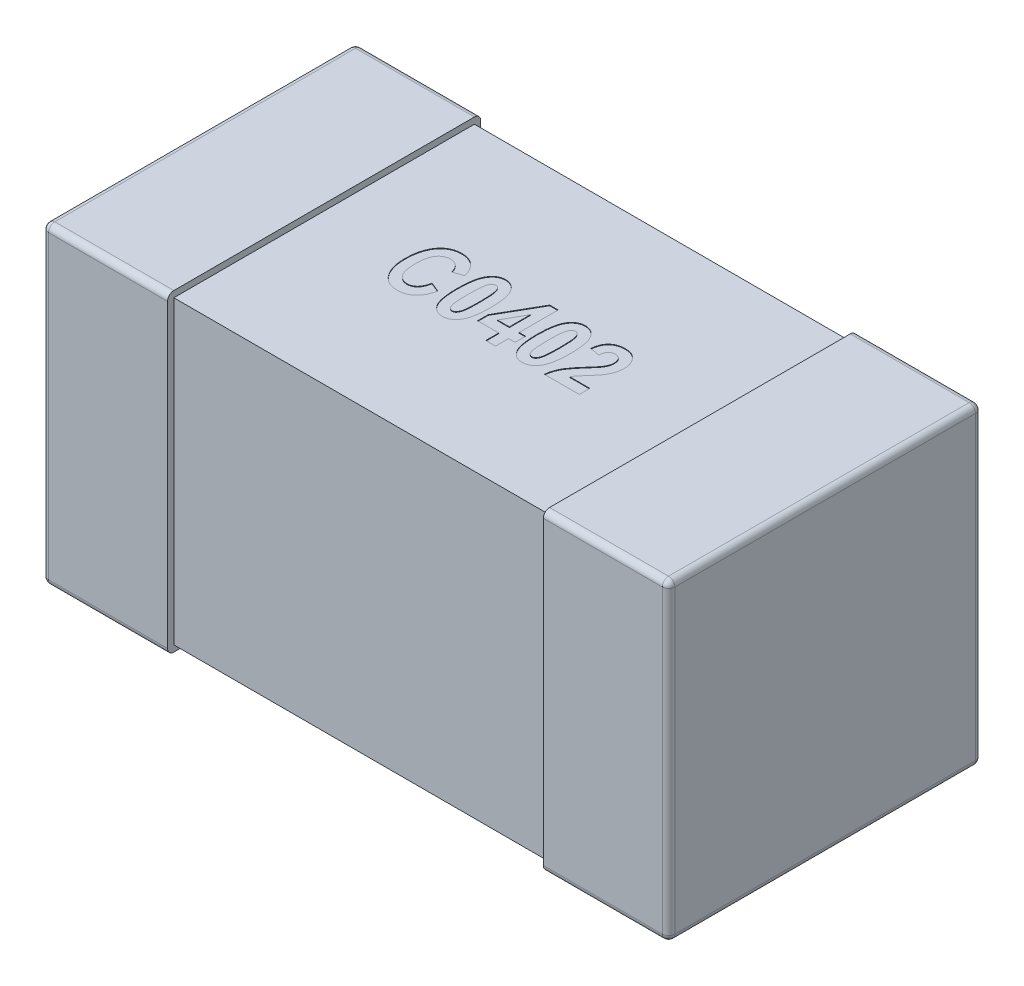
from build123d import *

# Parameters (mm, degrees)
SKETCH1_W            = 0.2
SKETCH1_H            = 0.5
THICKNESS_DEPTH      = 0.5
FILLET1_R            = 0.01
SKETCH2_W            = 0.48
SKETCH2_H            = 0.48
BOSS_EXTRUDE2_DEPTH  = 0.3
FILLET1_OF_MIRROR3_R = 0.01
CUT_EXTRUDE1_DEPTH   = 0.001


with BuildPart() as part:
    # Sketch1 → THICKNESS (new body)
    with BuildSketch(Plane(origin=(0, 0, 0), x_dir=(1, 0, 0), z_dir=(0, 1, 0))):
        with Locations((-0.4, 0)):
            Rectangle(SKETCH1_W, SKETCH1_H)
    thickness = extrude(amount=THICKNESS_DEPTH)

    # Fillet1
    fillet1_edges = [part.edges().sort_by_distance(p)[0] for p in [
        (-0.4, 0.5, -0.25),
        (-0.5, 0.5, 0),
        (-0.4, 0, -0.25),
        (-0.4, 0, 0.25),
        (-0.5, 0, 0),
        (-0.4, 0.5, 0.25),
        (-0.5, 0.25, -0.25),
        (-0.5, 0.25, 0.25),
    ]]
    fillet(fillet1_edges, radius=FILLET1_R)

    # Sketch2 → Boss-Extrude2 (add)
    with BuildSketch(Plane(origin=(0, 0, 0), x_dir=(0, 0, -1), z_dir=(1, 0, 0))):
        with Locations((0, 0.25)):
            Rectangle(SKETCH2_W, SKETCH2_H)
    boss_extrude2 = extrude(amount=-BOSS_EXTRUDE2_DEPTH)

    # Mirror3: THICKNESS, Boss-Extrude2 across plane
    add(thickness.mirror(Plane(origin=(0, 0, 0), x_dir=(0, 0, 1), z_dir=(1, 0, 0))))
    add(boss_extrude2.mirror(Plane(origin=(0, 0, 0), x_dir=(0, 0, 1), z_dir=(1, 0, 0))))

    # Fillet1 of Mirror3
    fillet1_of_mirror3_edges = [part.edges().sort_by_distance(p)[0] for p in [
        (0.4, 0.5, -0.25),
        (0.5, 0.5, 0),
        (0.4, 0, -0.25),
        (0.4, 0, 0.25),
        (0.5, 0, 0),
        (0.4, 0.5, 0.25),
        (0.5, 0.25, -0.25),
        (0.5, 0.25, 0.25),
    ]]
    fillet(fillet1_of_mirror3_edges, radius=FILLET1_OF_MIRROR3_R)

    # Sketch3 → Cut-Extrude1 (cut)
    with BuildSketch(Plane(origin=(0, 0.49, 0), x_dir=(1, 0, 0), z_dir=(0, 1, 0))):
        with BuildLine():
            Line((-0.113961039, -0.013636364), (-0.098376623, -0.02012987))
            add(Edge.make_bspline(
                [(-0.098376623, -0.02012987), (-0.098698486, -0.021439884), (-0.099325651, -0.02399251), (-0.100512161, -0.027640931), (-0.10181778, -0.031026109), (-0.103311482, -0.034129098), (-0.104942054, -0.03697712), (-0.106753288, -0.03954215), (-0.108711107, -0.041837321), (-0.110826647, -0.04385727), (-0.113096477, -0.045595275), (-0.115456865, -0.047144014), (-0.117968765, -0.04841365), (-0.120597002, -0.049485662), (-0.123362239, -0.050282525), (-0.126243467, -0.050882197), (-0.129253053, -0.051225358), (-0.131303272, -0.051273978), (-0.132345779, -0.051298701)],
                knots=[0, 0, 0, 0, 4.046e-06, 7.883e-06, 1.1501e-05, 1.4922e-05, 1.8205e-05, 2.1335e-05, 2.4328e-05, 2.7242e-05, 3.0091e-05, 3.2894e-05, 3.5699e-05, 3.8521e-05, 4.1398e-05, 4.4319e-05, 4.7342e-05, 5.0469e-05, 5.0469e-05, 5.0469e-05, 5.0469e-05], degree=3))
            add(Edge.make_bspline(
                [(-0.132345779, -0.051298701), (-0.133653808, -0.051269294), (-0.136216205, -0.051211685), (-0.139955235, -0.050591826), (-0.143513244, -0.049650059), (-0.146883819, -0.048297676), (-0.150070956, -0.046569042), (-0.153040987, -0.044427876), (-0.155863213, -0.041953888), (-0.157504143, -0.040024907), (-0.158340097, -0.039042208)],
                knots=[0, 0, 0, 0, 3.921e-06, 7.68e-06, 1.1338e-05, 1.4944e-05, 1.8549e-05, 2.2186e-05, 2.5909e-05, 2.9775e-05, 2.9775e-05, 2.9775e-05, 2.9775e-05], degree=3))
            add(Edge.make_bspline(
                [(-0.158340097, -0.039042208), (-0.159258979, -0.037828943), (-0.161110151, -0.035384708), (-0.163434195, -0.03135417), (-0.165410839, -0.027024034), (-0.167028624, -0.022390376), (-0.168289603, -0.017448062), (-0.16917119, -0.012194736), (-0.169700611, -0.006632938), (-0.169769805, -0.0028218), (-0.169805195, -0.000872565)],
                knots=[0, 0, 0, 0, 4.562e-06, 9.191e-06, 1.3922e-05, 1.8825e-05, 2.3894e-05, 2.9205e-05, 3.479e-05, 4.0637e-05, 4.0637e-05, 4.0637e-05, 4.0637e-05], degree=3))
            add(Edge.make_bspline(
                [(-0.169805195, -0.000872565), (-0.169772864, 0.001185129), (-0.169709888, 0.00519317), (-0.169142885, 0.011028498), (-0.168278515, 0.016529823), (-0.166989774, 0.021676699), (-0.165375342, 0.026498678), (-0.163380716, 0.030965691), (-0.161064755, 0.035124457), (-0.159175196, 0.037608213), (-0.158238636, 0.038839286)],
                knots=[0, 0, 0, 0, 6.172e-06, 1.2021e-05, 1.7572e-05, 2.2863e-05, 2.792e-05, 3.2807e-05, 3.7524e-05, 4.2159e-05, 4.2159e-05, 4.2159e-05, 4.2159e-05], degree=3))
            add(Edge.make_bspline(
                [(-0.158238636, 0.038839286), (-0.157388286, 0.039834414), (-0.155712429, 0.041795598), (-0.15284799, 0.044335194), (-0.149770684, 0.046493942), (-0.146481623, 0.048261407), (-0.142966091, 0.049636084), (-0.139241293, 0.050606078), (-0.135292315, 0.051178413), (-0.132591184, 0.051257992), (-0.131209416, 0.051298701)],
                knots=[0, 0, 0, 0, 3.923e-06, 7.732e-06, 1.1447e-05, 1.5178e-05, 1.8905e-05, 2.2744e-05, 2.6702e-05, 3.0846e-05, 3.0846e-05, 3.0846e-05, 3.0846e-05], degree=3))
            add(Edge.make_bspline(
                [(-0.131209416, 0.051298701), (-0.130078625, 0.051271634), (-0.127856109, 0.051218435), (-0.124597192, 0.05079314), (-0.121492273, 0.050045317), (-0.118511042, 0.049064406), (-0.115679656, 0.047751959), (-0.112989928, 0.04615938), (-0.110431279, 0.044291905), (-0.108880442, 0.042840118), (-0.108096591, 0.042106331)],
                knots=[0, 0, 0, 0, 3.392e-06, 6.666e-06, 9.836e-06, 1.2961e-05, 1.6066e-05, 1.9178e-05, 2.2327e-05, 2.5546e-05, 2.5546e-05, 2.5546e-05, 2.5546e-05], degree=3))
            add(Edge.make_bspline(
                [(-0.108096591, 0.042106331), (-0.107551587, 0.041540788), (-0.106441022, 0.04038837), (-0.104945644, 0.038447195), (-0.103561183, 0.036309366), (-0.102312462, 0.033965761), (-0.101151565, 0.031439285), (-0.100095942, 0.028716989), (-0.099167288, 0.025792679), (-0.09864425, 0.02376486), (-0.098376623, 0.022727273)],
                knots=[0, 0, 0, 0, 2.355e-06, 4.798e-06, 7.337e-06, 9.988e-06, 1.2757e-05, 1.5674e-05, 1.8742e-05, 2.1956e-05, 2.1956e-05, 2.1956e-05, 2.1956e-05], degree=3))
            Line((-0.098376623, 0.022727273), (-0.113961039, 0.017532468))
            add(Edge.make_bspline(
                [(-0.113961039, 0.017532468), (-0.114107485, 0.01819759), (-0.114392444, 0.019491808), (-0.11496457, 0.021359541), (-0.115661111, 0.023094294), (-0.116418956, 0.024737712), (-0.117331528, 0.026232951), (-0.118286107, 0.027651456), (-0.11940544, 0.028908196), (-0.120587985, 0.030069208), (-0.121875452, 0.031072515), (-0.123193291, 0.03197985), (-0.124580791, 0.032734233), (-0.126032164, 0.033340946), (-0.127530221, 0.03383196), (-0.129086123, 0.034177253), (-0.13069631, 0.034386351), (-0.131790487, 0.034405743), (-0.132345779, 0.034415584)],
                knots=[0, 0, 0, 0, 2.043e-06, 3.975e-06, 5.851e-06, 7.648e-06, 9.395e-06, 1.1101e-05, 1.277e-05, 1.4434e-05, 1.6066e-05, 1.7659e-05, 1.923e-05, 2.0794e-05, 2.2373e-05, 2.3953e-05, 2.5569e-05, 2.7234e-05, 2.7234e-05, 2.7234e-05, 2.7234e-05], degree=3))
            add(Edge.make_bspline(
                [(-0.132345779, 0.034415584), (-0.133131655, 0.034392284), (-0.134678339, 0.034346427), (-0.136944365, 0.033981575), (-0.139088333, 0.033336255), (-0.141142522, 0.032489077), (-0.143072413, 0.031360384), (-0.144899491, 0.02999352), (-0.146574628, 0.028347179), (-0.14818007, 0.026495327), (-0.149634872, 0.024349724), (-0.150870098, 0.021869978), (-0.151888935, 0.01906494), (-0.152766544, 0.01595473), (-0.153423156, 0.012518912), (-0.153878825, 0.008762806), (-0.154163213, 0.004691861), (-0.154201149, 0.001867371), (-0.154220779, 0.000405844)],
                knots=[0, 0, 0, 0, 2.357e-06, 4.639e-06, 6.861e-06, 9.061e-06, 1.1289e-05, 1.355e-05, 1.5889e-05, 1.8321e-05, 2.0893e-05, 2.3643e-05, 2.6609e-05, 2.9834e-05, 3.3328e-05, 3.7091e-05, 4.118e-05, 4.5564e-05, 4.5564e-05, 4.5564e-05, 4.5564e-05], degree=3))
            add(Edge.make_bspline(
                [(-0.154220779, 0.000405844), (-0.154198598, -0.001109587), (-0.154155885, -0.004027849), (-0.1539069, -0.008242797), (-0.15343364, -0.012115369), (-0.15282783, -0.015660792), (-0.151998836, -0.018858342), (-0.15098606, -0.021709979), (-0.149819503, -0.024243541), (-0.148427925, -0.026425789), (-0.14688603, -0.028309718), (-0.145246714, -0.029945379), (-0.143478327, -0.031311746), (-0.141628178, -0.032469734), (-0.139645475, -0.033347227), (-0.137553673, -0.033944253), (-0.135365177, -0.034357187), (-0.133862911, -0.034395858), (-0.133096591, -0.034415584)],
                knots=[0, 0, 0, 0, 4.547e-06, 8.755e-06, 1.2659e-05, 1.6246e-05, 1.9538e-05, 2.2555e-05, 2.5314e-05, 2.7887e-05, 3.0296e-05, 3.2606e-05, 3.4818e-05, 3.6986e-05, 3.9139e-05, 4.1297e-05, 4.3502e-05, 4.5798e-05, 4.5798e-05, 4.5798e-05, 4.5798e-05], degree=3))
            add(Edge.make_bspline(
                [(-0.133096591, -0.034415584), (-0.13253456, -0.034398178), (-0.131419647, -0.034363648), (-0.129779044, -0.034143775), (-0.128195889, -0.033750644), (-0.126669969, -0.033205221), (-0.125207788, -0.032485604), (-0.123794343, -0.031633067), (-0.122458188, -0.030608308), (-0.121164654, -0.029444744), (-0.119944617, -0.028106441), (-0.118829596, -0.026567769), (-0.117793616, -0.024856228), (-0.11684294, -0.022961204), (-0.115971504, -0.020894877), (-0.115203153, -0.018641389), (-0.114507867, -0.016211992), (-0.114146826, -0.014511443), (-0.113961039, -0.013636364)],
                knots=[0, 0, 0, 0, 1.686e-06, 3.345e-06, 4.954e-06, 6.572e-06, 8.196e-06, 9.836e-06, 1.1516e-05, 1.324e-05, 1.505e-05, 1.6937e-05, 1.8931e-05, 2.1046e-05, 2.3292e-05, 2.5653e-05, 2.8184e-05, 3.0867e-05, 3.0867e-05, 3.0867e-05, 3.0867e-05], degree=3))
        make_face()
        with BuildLine():
            add(Edge.make_bspline(
                [(-0.060105519, 0.05), (-0.059135833, 0.049964358), (-0.057222431, 0.04989403), (-0.054430725, 0.049353346), (-0.05177303, 0.048474931), (-0.049267708, 0.047228793), (-0.046913228, 0.045623783), (-0.044703675, 0.043669691), (-0.042637317, 0.041367355), (-0.040700866, 0.038696109), (-0.038960707, 0.035571953), (-0.037474493, 0.031938666), (-0.036226319, 0.027783702), (-0.035209238, 0.023107565), (-0.034402419, 0.017903612), (-0.03385603, 0.012171365), (-0.033508159, 0.005916099), (-0.03346434, 0.001569766), (-0.033441558, -0.000689935)],
                knots=[0, 0, 0, 0, 2.908e-06, 5.737e-06, 8.496e-06, 1.1282e-05, 1.4102e-05, 1.7021e-05, 2.011e-05, 2.3365e-05, 2.6899e-05, 3.0811e-05, 3.5118e-05, 3.9899e-05, 4.5157e-05, 5.0907e-05, 5.7167e-05, 6.3945e-05, 6.3945e-05, 6.3945e-05, 6.3945e-05], degree=3))
            add(Edge.make_bspline(
                [(-0.033441558, -0.000689935), (-0.03346439, -0.002942863), (-0.0335083, -0.007275659), (-0.033855394, -0.013510801), (-0.034404852, -0.019228969), (-0.035205117, -0.024420833), (-0.036234404, -0.029093584), (-0.037464982, -0.033247664), (-0.03896674, -0.036874757), (-0.04069899, -0.039996177), (-0.042639034, -0.042658568), (-0.044682891, -0.044974739), (-0.046893553, -0.046922402), (-0.049243536, -0.048521381), (-0.051736609, -0.049779209), (-0.054378271, -0.050644957), (-0.057153868, -0.051196681), (-0.059054431, -0.051264229), (-0.060024351, -0.051298701)],
                knots=[0, 0, 0, 0, 6.758e-06, 1.2998e-05, 1.8728e-05, 2.3986e-05, 2.8747e-05, 3.3073e-05, 3.6966e-05, 4.05e-05, 4.3755e-05, 4.6831e-05, 4.975e-05, 5.2569e-05, 5.5337e-05, 5.8097e-05, 6.0886e-05, 6.3794e-05, 6.3794e-05, 6.3794e-05, 6.3794e-05], degree=3))
            add(Edge.make_bspline(
                [(-0.060024351, -0.051298701), (-0.060993624, -0.051260783), (-0.062904973, -0.05118601), (-0.065701418, -0.050678537), (-0.068357188, -0.049793153), (-0.070856238, -0.048545911), (-0.073216809, -0.046965179), (-0.075425233, -0.045029503), (-0.077494379, -0.042749375), (-0.079067423, -0.040579421), (-0.080250242, -0.038660986), (-0.081075372, -0.03705636), (-0.081844428, -0.035318492), (-0.082584679, -0.033457201), (-0.083218993, -0.031436073), (-0.083830918, -0.029293436), (-0.084380231, -0.027012105), (-0.084854209, -0.02459915), (-0.085317701, -0.022059662), (-0.085662221, -0.019375042), (-0.086003117, -0.016563625), (-0.086229321, -0.013604025), (-0.086441109, -0.010520159), (-0.086571584, -0.007292376), (-0.086688752, -0.003937524), (-0.08668846, -0.001650549), (-0.086688312, -0.000487013)],
                knots=[0, 0, 0, 0, 2.908e-06, 5.733e-06, 8.493e-06, 1.1279e-05, 1.4087e-05, 1.6993e-05, 2.0067e-05, 2.3306e-05, 2.5018e-05, 2.6824e-05, 2.8713e-05, 3.0718e-05, 3.2829e-05, 3.5065e-05, 3.7403e-05, 3.9866e-05, 4.2441e-05, 4.5145e-05, 4.7984e-05, 5.0936e-05, 5.4048e-05, 5.7257e-05, 6.0627e-05, 6.4117e-05, 6.4117e-05, 6.4117e-05, 6.4117e-05], degree=3))
            add(Edge.make_bspline(
                [(-0.086688312, -0.000487013), (-0.086665546, 0.001759163), (-0.086621769, 0.006078464), (-0.086273918, 0.012293193), (-0.085727801, 0.017984944), (-0.084919434, 0.023154987), (-0.083899737, 0.027809667), (-0.082660664, 0.03195444), (-0.081163532, 0.035576174), (-0.079430786, 0.038697448), (-0.077490859, 0.041359874), (-0.075446973, 0.043676036), (-0.073236318, 0.045623701), (-0.070886334, 0.047222679), (-0.068393261, 0.048480507), (-0.065751599, 0.049346256), (-0.062976002, 0.04989798), (-0.061075439, 0.049965528), (-0.060105519, 0.05)],
                knots=[0, 0, 0, 0, 6.738e-06, 1.2957e-05, 1.8667e-05, 2.3885e-05, 2.8646e-05, 3.2953e-05, 3.6846e-05, 4.038e-05, 4.3635e-05, 4.6711e-05, 4.9629e-05, 5.2449e-05, 5.5217e-05, 5.7976e-05, 6.0766e-05, 6.3674e-05, 6.3674e-05, 6.3674e-05, 6.3674e-05], degree=3))
        make_face()
        with BuildLine():
            add(Edge.make_bspline(
                [(-0.060064935, 0.034415584), (-0.060425329, 0.034394855), (-0.061143756, 0.034353533), (-0.062188536, 0.034057142), (-0.063182664, 0.033585573), (-0.064107287, 0.032899207), (-0.064955987, 0.032007152), (-0.065770979, 0.030949167), (-0.066520341, 0.029694681), (-0.067239852, 0.028212894), (-0.067851283, 0.026352172), (-0.068389733, 0.0240316), (-0.068813314, 0.021187046), (-0.069167748, 0.017821504), (-0.069475657, 0.013938204), (-0.069662169, 0.009525336), (-0.069785649, 0.004593524), (-0.069798463, 0.001129691), (-0.069805195, -0.000689935)],
                knots=[0, 0, 0, 0, 1.08e-06, 2.153e-06, 3.234e-06, 4.366e-06, 5.586e-06, 6.917e-06, 8.365e-06, 9.962e-06, 1.1849e-05, 1.4226e-05, 1.7102e-05, 2.047e-05, 2.4378e-05, 2.8786e-05, 3.3718e-05, 3.9177e-05, 3.9177e-05, 3.9177e-05, 3.9177e-05], degree=3))
            add(Edge.make_bspline(
                [(-0.069805195, -0.000689935), (-0.069798585, -0.002509567), (-0.069786027, -0.005966648), (-0.069661376, -0.010891633), (-0.069477193, -0.015291155), (-0.069164603, -0.019174004), (-0.068817031, -0.022533553), (-0.068387777, -0.025377486), (-0.067850122, -0.027690867), (-0.067245349, -0.029548041), (-0.066515202, -0.031018145), (-0.065770242, -0.032267148), (-0.06496307, -0.033326476), (-0.064100182, -0.034197609), (-0.06318346, -0.034885062), (-0.062188329, -0.035355638), (-0.061143808, -0.035652285), (-0.060425346, -0.035693574), (-0.060064935, -0.035714286)],
                knots=[0, 0, 0, 0, 5.459e-06, 1.0371e-05, 1.4779e-05, 1.8667e-05, 2.2055e-05, 2.4911e-05, 2.7288e-05, 2.9175e-05, 3.0754e-05, 3.2202e-05, 3.3533e-05, 3.4738e-05, 3.5871e-05, 3.6951e-05, 3.8024e-05, 3.9104e-05, 3.9104e-05, 3.9104e-05, 3.9104e-05], degree=3))
            add(Edge.make_bspline(
                [(-0.060064935, -0.035714286), (-0.059697772, -0.035694004), (-0.058972547, -0.035653942), (-0.057920313, -0.035356782), (-0.056924763, -0.034878173), (-0.055982179, -0.034206212), (-0.05514205, -0.033305541), (-0.054308408, -0.032272815), (-0.053594832, -0.031005894), (-0.052868557, -0.029533173), (-0.052253198, -0.027673481), (-0.051753763, -0.025345265), (-0.051285942, -0.022509053), (-0.050940659, -0.019147476), (-0.050660453, -0.015269867), (-0.050466034, -0.010871493), (-0.050344737, -0.005953073), (-0.050331586, -0.002502786), (-0.050324675, -0.000689935)],
                knots=[0, 0, 0, 0, 1.1e-06, 2.174e-06, 3.254e-06, 4.403e-06, 5.622e-06, 6.937e-06, 8.375e-06, 9.972e-06, 1.1859e-05, 1.4232e-05, 1.7111e-05, 2.0479e-05, 2.4365e-05, 2.8773e-05, 3.3685e-05, 3.9124e-05, 3.9124e-05, 3.9124e-05, 3.9124e-05], degree=3))
            add(Edge.make_bspline(
                [(-0.050324675, -0.000689935), (-0.05033164, 0.001129677), (-0.050344898, 0.004593485), (-0.050465399, 0.00952547), (-0.050661468, 0.013937273), (-0.050939572, 0.017821793), (-0.051286008, 0.021190069), (-0.051753802, 0.024026228), (-0.052253043, 0.02635461), (-0.052868988, 0.028213847), (-0.053593541, 0.029687898), (-0.054315213, 0.030955261), (-0.055135246, 0.032005366), (-0.05598294, 0.03290692), (-0.056924578, 0.033579615), (-0.057920361, 0.034058043), (-0.058972534, 0.03435525), (-0.059697768, 0.034395306), (-0.060064935, 0.034415584)],
                knots=[0, 0, 0, 0, 5.459e-06, 1.0391e-05, 1.4799e-05, 1.8706e-05, 2.2074e-05, 2.4953e-05, 2.7326e-05, 2.9212e-05, 3.081e-05, 3.2247e-05, 3.3578e-05, 3.4798e-05, 3.5947e-05, 3.7027e-05, 3.81e-05, 3.92e-05, 3.92e-05, 3.92e-05, 3.92e-05], degree=3))
        make_face(mode=Mode.SUBTRACT)
        Polygon((0.008116883, -0.05), (0.008116883, -0.029220779), (-0.025649351, -0.029220779), (-0.025649351, -0.012398539), (0.010146104, 0.05), (0.023701299, 0.05), (0.023701299, -0.012337662), (0.034090909, -0.012337662), (0.034090909, -0.029220779), (0.023701299, -0.029220779), (0.023701299, -0.05), align=None)
        Polygon((0.008116883, -0.012337662), (0.008116883, 0.021245942), (-0.010815747, -0.012337662), align=None, mode=Mode.SUBTRACT)
        with BuildLine():
            add(Edge.make_bspline(
                [(0.067167208, 0.05), (0.068136894, 0.049964358), (0.070050296, 0.04989403), (0.072842002, 0.049353346), (0.075499697, 0.048474931), (0.078005019, 0.047228793), (0.080359499, 0.045623783), (0.082569052, 0.043669691), (0.08463541, 0.041367355), (0.086571861, 0.038696109), (0.088312021, 0.035571953), (0.089798234, 0.031938666), (0.091046408, 0.027783702), (0.092063489, 0.023107565), (0.092870309, 0.017903612), (0.093416697, 0.012171365), (0.093764568, 0.005916099), (0.093808387, 0.001569766), (0.093831169, -0.000689935)],
                knots=[0, 0, 0, 0, 2.908e-06, 5.737e-06, 8.496e-06, 1.1282e-05, 1.4102e-05, 1.7021e-05, 2.011e-05, 2.3365e-05, 2.6899e-05, 3.0811e-05, 3.5118e-05, 3.9899e-05, 4.5157e-05, 5.0907e-05, 5.7167e-05, 6.3945e-05, 6.3945e-05, 6.3945e-05, 6.3945e-05], degree=3))
            add(Edge.make_bspline(
                [(0.093831169, -0.000689935), (0.093808337, -0.002942863), (0.093764427, -0.007275659), (0.093417333, -0.013510801), (0.092867876, -0.019228969), (0.09206761, -0.024420833), (0.091038323, -0.029093584), (0.089807745, -0.033247664), (0.088305987, -0.036874757), (0.086573738, -0.039996177), (0.084633693, -0.042658568), (0.082589836, -0.044974739), (0.080379174, -0.046922402), (0.078029192, -0.048521381), (0.075536118, -0.049779209), (0.072894456, -0.050644957), (0.070118859, -0.051196681), (0.068218296, -0.051264229), (0.067248377, -0.051298701)],
                knots=[0, 0, 0, 0, 6.758e-06, 1.2998e-05, 1.8728e-05, 2.3986e-05, 2.8747e-05, 3.3073e-05, 3.6966e-05, 4.05e-05, 4.3755e-05, 4.6831e-05, 4.975e-05, 5.2569e-05, 5.5337e-05, 5.8097e-05, 6.0886e-05, 6.3794e-05, 6.3794e-05, 6.3794e-05, 6.3794e-05], degree=3))
            add(Edge.make_bspline(
                [(0.067248377, -0.051298701), (0.066279103, -0.051260783), (0.064367754, -0.05118601), (0.06157131, -0.050678537), (0.058915539, -0.049793153), (0.056416489, -0.048545911), (0.054055918, -0.046965179), (0.051847494, -0.045029503), (0.049778348, -0.042749375), (0.048205304, -0.040579421), (0.047022485, -0.038660986), (0.046197355, -0.03705636), (0.045428299, -0.035318492), (0.044688048, -0.033457201), (0.044053734, -0.031436073), (0.043441809, -0.029293436), (0.042892496, -0.027012105), (0.042418518, -0.02459915), (0.041955026, -0.022059662), (0.041610506, -0.019375042), (0.041269611, -0.016563625), (0.041043407, -0.013604025), (0.040831618, -0.010520159), (0.040701143, -0.007292376), (0.040583975, -0.003937524), (0.040584267, -0.001650549), (0.040584416, -0.000487013)],
                knots=[0, 0, 0, 0, 2.908e-06, 5.733e-06, 8.493e-06, 1.1279e-05, 1.4087e-05, 1.6993e-05, 2.0067e-05, 2.3306e-05, 2.5018e-05, 2.6824e-05, 2.8713e-05, 3.0718e-05, 3.2829e-05, 3.5065e-05, 3.7403e-05, 3.9866e-05, 4.2441e-05, 4.5145e-05, 4.7984e-05, 5.0936e-05, 5.4048e-05, 5.7257e-05, 6.0627e-05, 6.4117e-05, 6.4117e-05, 6.4117e-05, 6.4117e-05], degree=3))
            add(Edge.make_bspline(
                [(0.040584416, -0.000487013), (0.040607181, 0.001759163), (0.040650959, 0.006078464), (0.04099881, 0.012293193), (0.041544927, 0.017984944), (0.042353293, 0.023154987), (0.043372991, 0.027809667), (0.044612063, 0.03195444), (0.046109195, 0.035576174), (0.047841941, 0.038697448), (0.049781868, 0.041359874), (0.051825754, 0.043676036), (0.054036409, 0.045623701), (0.056386393, 0.047222679), (0.058879466, 0.048480507), (0.061521128, 0.049346256), (0.064296725, 0.04989798), (0.066197288, 0.049965528), (0.067167208, 0.05)],
                knots=[0, 0, 0, 0, 6.738e-06, 1.2957e-05, 1.8667e-05, 2.3885e-05, 2.8646e-05, 3.2953e-05, 3.6846e-05, 4.038e-05, 4.3635e-05, 4.6711e-05, 4.9629e-05, 5.2449e-05, 5.5217e-05, 5.7976e-05, 6.0766e-05, 6.3674e-05, 6.3674e-05, 6.3674e-05, 6.3674e-05], degree=3))
        make_face()
        with BuildLine():
            add(Edge.make_bspline(
                [(0.067207792, 0.034415584), (0.066847398, 0.034394855), (0.066128971, 0.034353533), (0.065084192, 0.034057142), (0.064090063, 0.033585573), (0.06316544, 0.032899207), (0.062316741, 0.032007152), (0.061501748, 0.030949167), (0.060752386, 0.029694681), (0.060032875, 0.028212894), (0.059421444, 0.026352172), (0.058882994, 0.0240316), (0.058459413, 0.021187046), (0.058104979, 0.017821504), (0.057797071, 0.013938204), (0.057610558, 0.009525336), (0.057487078, 0.004593524), (0.057474264, 0.001129691), (0.057467532, -0.000689935)],
                knots=[0, 0, 0, 0, 1.08e-06, 2.153e-06, 3.234e-06, 4.366e-06, 5.586e-06, 6.917e-06, 8.365e-06, 9.962e-06, 1.1849e-05, 1.4226e-05, 1.7102e-05, 2.047e-05, 2.4378e-05, 2.8786e-05, 3.3718e-05, 3.9177e-05, 3.9177e-05, 3.9177e-05, 3.9177e-05], degree=3))
            add(Edge.make_bspline(
                [(0.057467532, -0.000689935), (0.057474142, -0.002509567), (0.057486701, -0.005966648), (0.057611352, -0.010891633), (0.057795534, -0.015291155), (0.058108125, -0.019174004), (0.058455696, -0.022533553), (0.05888495, -0.025377486), (0.059422606, -0.027690867), (0.060027379, -0.029548041), (0.060757526, -0.031018145), (0.061502485, -0.032267148), (0.062309657, -0.033326476), (0.063172545, -0.034197609), (0.064089267, -0.034885062), (0.065084398, -0.035355638), (0.066128919, -0.035652285), (0.066847381, -0.035693574), (0.067207792, -0.035714286)],
                knots=[0, 0, 0, 0, 5.459e-06, 1.0371e-05, 1.4779e-05, 1.8667e-05, 2.2055e-05, 2.4911e-05, 2.7288e-05, 2.9175e-05, 3.0754e-05, 3.2202e-05, 3.3533e-05, 3.4738e-05, 3.5871e-05, 3.6951e-05, 3.8024e-05, 3.9104e-05, 3.9104e-05, 3.9104e-05, 3.9104e-05], degree=3))
            add(Edge.make_bspline(
                [(0.067207792, -0.035714286), (0.067574955, -0.035694004), (0.068300181, -0.035653942), (0.069352414, -0.035356782), (0.070347964, -0.034878173), (0.071290549, -0.034206212), (0.072130677, -0.033305541), (0.072964319, -0.032272815), (0.073677896, -0.031005894), (0.07440417, -0.029533173), (0.075019529, -0.027673481), (0.075518965, -0.025345265), (0.075986785, -0.022509053), (0.076332068, -0.019147476), (0.076612274, -0.015269867), (0.076806693, -0.010871493), (0.07692799, -0.005953073), (0.076941142, -0.002502786), (0.076948052, -0.000689935)],
                knots=[0, 0, 0, 0, 1.1e-06, 2.174e-06, 3.254e-06, 4.403e-06, 5.622e-06, 6.937e-06, 8.375e-06, 9.972e-06, 1.1859e-05, 1.4232e-05, 1.7111e-05, 2.0479e-05, 2.4365e-05, 2.8773e-05, 3.3685e-05, 3.9124e-05, 3.9124e-05, 3.9124e-05, 3.9124e-05], degree=3))
            add(Edge.make_bspline(
                [(0.076948052, -0.000689935), (0.076941087, 0.001129677), (0.076927829, 0.004593485), (0.076807328, 0.00952547), (0.076611259, 0.013937273), (0.076333155, 0.017821793), (0.075986719, 0.021190069), (0.075518925, 0.024026228), (0.075019684, 0.02635461), (0.074403739, 0.028213847), (0.073679187, 0.029687898), (0.072957514, 0.030955261), (0.072137481, 0.032005366), (0.071289787, 0.03290692), (0.07034815, 0.033579615), (0.069352366, 0.034058043), (0.068300193, 0.03435525), (0.06757496, 0.034395306), (0.067207792, 0.034415584)],
                knots=[0, 0, 0, 0, 5.459e-06, 1.0391e-05, 1.4799e-05, 1.8706e-05, 2.2074e-05, 2.4953e-05, 2.7326e-05, 2.9212e-05, 3.081e-05, 3.2247e-05, 3.3578e-05, 3.4798e-05, 3.5947e-05, 3.7027e-05, 3.81e-05, 3.92e-05, 3.92e-05, 3.92e-05, 3.92e-05], degree=3))
        make_face(mode=Mode.SUBTRACT)
        with BuildLine():
            Line((0.157467532, -0.033116883), (0.157467532, -0.05))
            Line((0.157467532, -0.05), (0.101623377, -0.05))
            add(Edge.make_bspline(
                [(0.101623377, -0.05), (0.101819862, -0.048337188), (0.102212298, -0.045016081), (0.103400615, -0.040141698), (0.105002447, -0.03537986), (0.10675646, -0.031502419), (0.108497098, -0.028371679), (0.110054216, -0.025817251), (0.111908576, -0.023099077), (0.11405796, -0.020220842), (0.116441239, -0.017139892), (0.119111122, -0.013888544), (0.122053704, -0.010463932), (0.124130152, -0.008140373), (0.125202922, -0.006939935)],
                knots=[0, 0, 0, 0, 5.019e-06, 1.0025e-05, 1.5017e-05, 2.0076e-05, 2.2764e-05, 2.576e-05, 2.9047e-05, 3.2631e-05, 3.6536e-05, 4.0732e-05, 4.5251e-05, 5.008e-05, 5.008e-05, 5.008e-05, 5.008e-05], degree=3))
            add(Edge.make_bspline(
                [(0.125202922, -0.006939935), (0.126044044, -0.006001823), (0.127653185, -0.004207131), (0.129916582, -0.001608249), (0.131952501, 0.000728779), (0.13369606, 0.002852199), (0.135208695, 0.00471761), (0.136462299, 0.006353451), (0.137471904, 0.007745539), (0.138011539, 0.00862139), (0.138250812, 0.00900974)],
                knots=[0, 0, 0, 0, 3.78e-06, 7.231e-06, 1.0339e-05, 1.3077e-05, 1.5473e-05, 1.7543e-05, 1.9261e-05, 2.0629e-05, 2.0629e-05, 2.0629e-05, 2.0629e-05], degree=3))
            add(Edge.make_bspline(
                [(0.138250812, 0.00900974), (0.138806128, 0.010004517), (0.139890119, 0.011946345), (0.141018923, 0.015023514), (0.141756756, 0.018106231), (0.141841308, 0.020179947), (0.141883117, 0.021205357)],
                knots=[0, 0, 0, 0, 3.413e-06, 6.662e-06, 9.803e-06, 1.2875e-05, 1.2875e-05, 1.2875e-05, 1.2875e-05], degree=3))
            add(Edge.make_bspline(
                [(0.141883117, 0.021205357), (0.141847206, 0.022229899), (0.141779224, 0.024169422), (0.141197414, 0.026879266), (0.140224771, 0.029209695), (0.138818912, 0.031101808), (0.137107405, 0.032587044), (0.135133306, 0.033670857), (0.132899109, 0.034312894), (0.131328632, 0.034380666), (0.130519481, 0.034415584)],
                knots=[0, 0, 0, 0, 3.071e-06, 5.813e-06, 8.267e-06, 1.0589e-05, 1.2818e-05, 1.5016e-05, 1.7296e-05, 1.9719e-05, 1.9719e-05, 1.9719e-05, 1.9719e-05], degree=3))
            add(Edge.make_bspline(
                [(0.130519481, 0.034415584), (0.129642041, 0.034377242), (0.127960275, 0.034303752), (0.125594936, 0.033619552), (0.123541944, 0.032491691), (0.121859578, 0.030854766), (0.120478818, 0.028809704), (0.119481938, 0.026295861), (0.118798455, 0.023360996), (0.118607694, 0.021249853), (0.118506494, 0.02012987)],
                knots=[0, 0, 0, 0, 2.627e-06, 5.035e-06, 7.316e-06, 9.584e-06, 1.2009e-05, 1.4666e-05, 1.7649e-05, 2.1019e-05, 2.1019e-05, 2.1019e-05, 2.1019e-05], degree=3))
            Line((0.118506494, 0.02012987), (0.102922078, 0.022727273))
            add(Edge.make_bspline(
                [(0.102922078, 0.022727273), (0.103052576, 0.023866493), (0.103305727, 0.026076446), (0.103976058, 0.029250736), (0.104769922, 0.032201262), (0.105763938, 0.034912755), (0.106942719, 0.037388751), (0.108310258, 0.039626521), (0.109827126, 0.04166372), (0.111569875, 0.043431516), (0.113468964, 0.044978106), (0.115511575, 0.046331784), (0.117712746, 0.047463714), (0.120053278, 0.048407617), (0.122554355, 0.049106439), (0.125190533, 0.04964142), (0.127982689, 0.049943164), (0.129889728, 0.049980776), (0.130864448, 0.05)],
                knots=[0, 0, 0, 0, 3.438e-06, 6.67e-06, 9.722e-06, 1.2598e-05, 1.5321e-05, 1.7935e-05, 2.0455e-05, 2.2923e-05, 2.536e-05, 2.7792e-05, 3.026e-05, 3.2774e-05, 3.5349e-05, 3.8039e-05, 4.0836e-05, 4.376e-05, 4.376e-05, 4.376e-05, 4.376e-05], degree=3))
            add(Edge.make_bspline(
                [(0.130864448, 0.05), (0.131934886, 0.049982761), (0.134009689, 0.049949348), (0.137015283, 0.049515741), (0.139829383, 0.048897943), (0.142424301, 0.047936975), (0.144845405, 0.046781024), (0.147022553, 0.045284567), (0.149045048, 0.043588511), (0.150779067, 0.041574973), (0.152357536, 0.039446654), (0.153712832, 0.037203525), (0.154886299, 0.034905133), (0.155821388, 0.032510376), (0.156549373, 0.030037851), (0.157074004, 0.027492826), (0.157417646, 0.024874109), (0.157450731, 0.023100397), (0.157467532, 0.022199675)],
                knots=[0, 0, 0, 0, 3.208e-06, 6.219e-06, 9.094e-06, 1.1834e-05, 1.4503e-05, 1.712e-05, 1.9739e-05, 2.2398e-05, 2.5069e-05, 2.7682e-05, 3.025e-05, 3.2802e-05, 3.5383e-05, 3.7974e-05, 4.0591e-05, 4.3292e-05, 4.3292e-05, 4.3292e-05, 4.3292e-05], degree=3))
            add(Edge.make_bspline(
                [(0.157467532, 0.022199675), (0.157450481, 0.021177318), (0.157416629, 0.01914763), (0.157068965, 0.01612517), (0.15655548, 0.01314483), (0.155793774, 0.010202601), (0.154808807, 0.007283516), (0.153609411, 0.004362304), (0.152188236, 0.001429377), (0.150788776, -0.001000728), (0.149534833, -0.00301962), (0.148418236, -0.004633337), (0.147145707, -0.006341424), (0.145752923, -0.00817262), (0.144185272, -0.010091678), (0.142480983, -0.012121436), (0.140634098, -0.014252354), (0.139341935, -0.01569451), (0.138676948, -0.016436688)],
                knots=[0, 0, 0, 0, 3.066e-06, 6.087e-06, 9.116e-06, 1.2133e-05, 1.5194e-05, 1.8352e-05, 2.1601e-05, 2.4963e-05, 2.6759e-05, 2.8729e-05, 3.0848e-05, 3.3149e-05, 3.5631e-05, 3.8281e-05, 4.11e-05, 4.409e-05, 4.409e-05, 4.409e-05, 4.409e-05], degree=3))
            add(Edge.make_bspline(
                [(0.138676948, -0.016436688), (0.138061189, -0.017119641), (0.136887235, -0.0184217), (0.135212778, -0.020286237), (0.133746878, -0.021996709), (0.132418286, -0.023490866), (0.131285061, -0.024812573), (0.130318314, -0.025945404), (0.129561076, -0.026922714), (0.12841413, -0.028350567), (0.127036692, -0.030360416), (0.12605897, -0.032221364), (0.125588474, -0.033116883)],
                knots=[0, 0, 0, 0, 2.759e-06, 5.259e-06, 7.518e-06, 9.516e-06, 1.1257e-05, 1.2741e-05, 1.3983e-05, 1.4966e-05, 1.8236e-05, 2.1269e-05, 2.1269e-05, 2.1269e-05, 2.1269e-05], degree=3))
            Line((0.125588474, -0.033116883), (0.157467532, -0.033116883))
        make_face()
    extrude(amount=-CUT_EXTRUDE1_DEPTH, mode=Mode.SUBTRACT)


solid = part.part
